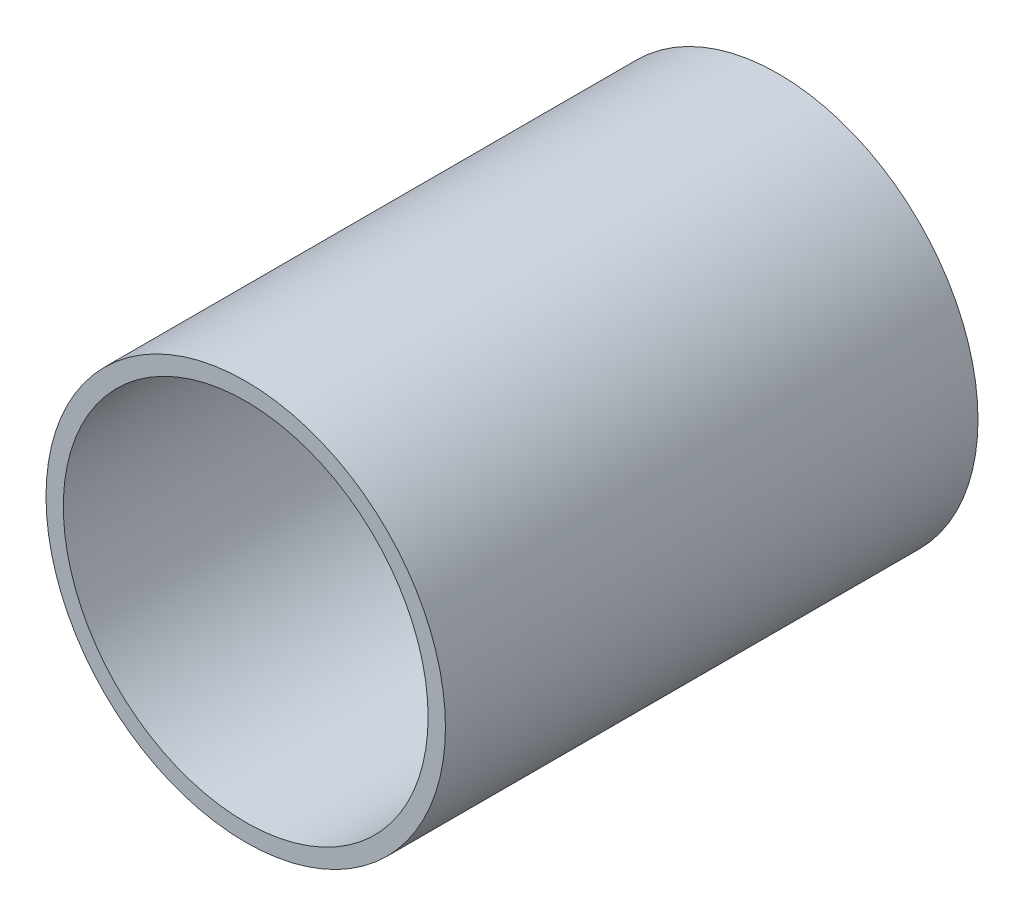
from build123d import *

# Parameters (mm, degrees)
SKETCH1_R      = 19.05
SKETCH1_R_2    = 17.399
EXTRUDE1_DEPTH = 50.8


with BuildPart() as part:
    # Sketch1 → Extrude1 (new body)
    with BuildSketch(Plane.XY):
        Circle(SKETCH1_R)
        Circle(SKETCH1_R_2, mode=Mode.SUBTRACT)
    extrude(amount=EXTRUDE1_DEPTH)


solid = part.part
